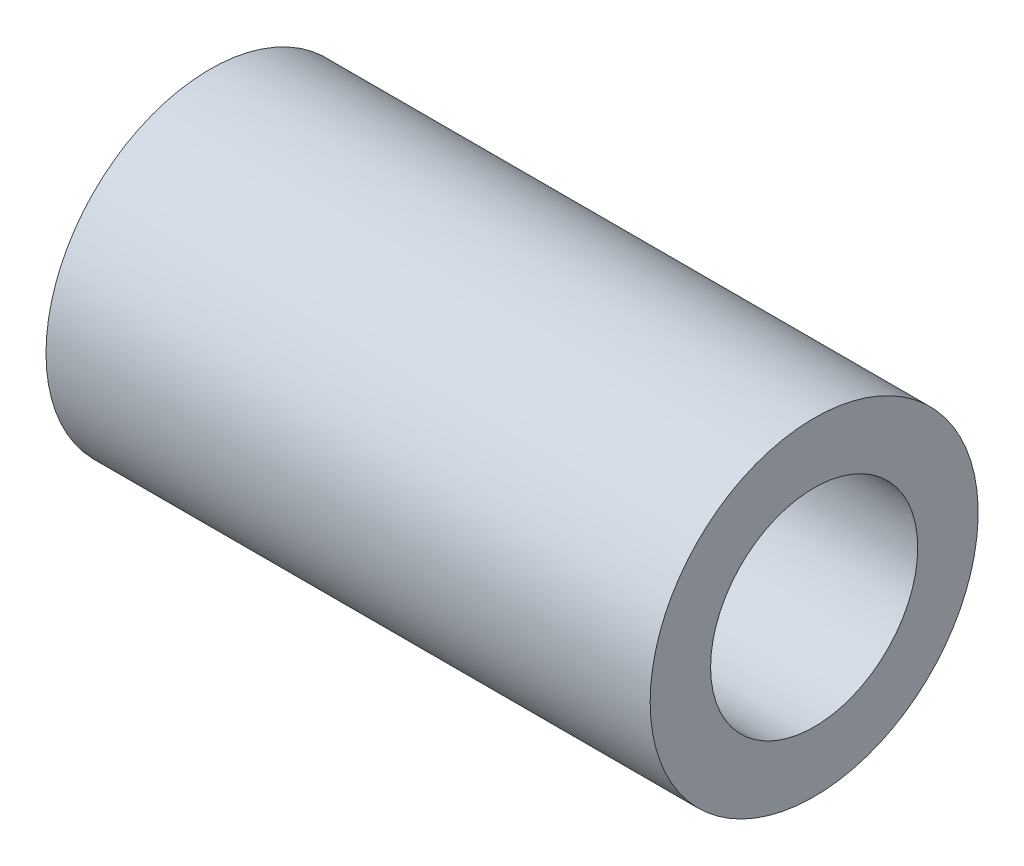
from build123d import *

# Parameters (mm, degrees)
ESBO_O1_W = 55.5625
ESBO_O1_H = 5.55625


with BuildPart() as part:
    # Esboço1 → Revolução1 (revolve)
    with BuildSketch(Plane.XY):
        with Locations((27.78125, 12.303125)):
            Rectangle(ESBO_O1_W, ESBO_O1_H)
    revolve(axis=Axis((55.5625, 0, 0), (-1, 0, 0)))


solid = part.part
